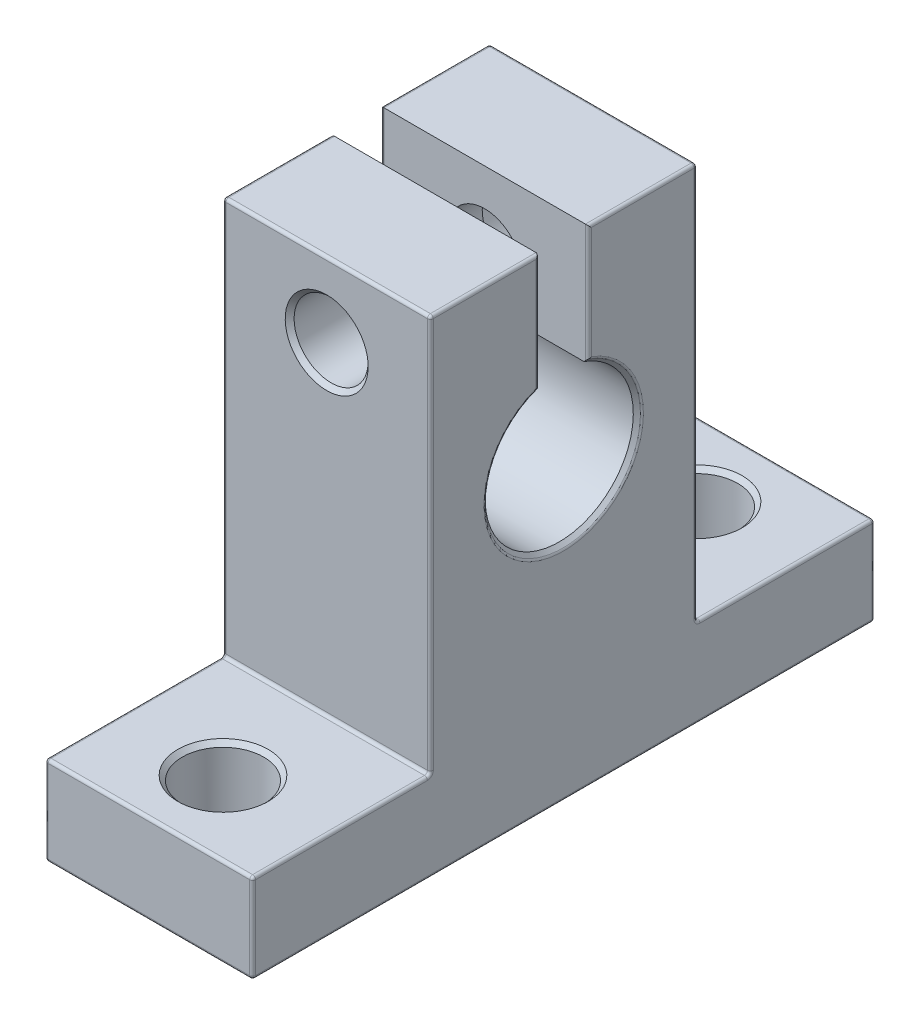
from build123d import *

# Parameters (mm, degrees)
BOSS_EXTRUDE1_DEPTH = 7
SKETCH2_R           = 2.75
CUT_EXTRUDE1_DEPTH  = 7
SKETCH3_R           = 2.5
CUT_EXTRUDE2_DEPTH  = 31
SKETCH4_R           = 4
CUT_EXTRUDE3_DEPTH  = 5
CHAMFER_1_SIZE      = 0.3
FILLET_1_R          = 0.2


with BuildPart() as part:
    # Sketch1 → Boss-Extrude1 (new body, symmetric)
    with BuildSketch(Plane(origin=(0, 0, 0), x_dir=(0, 0, -1), z_dir=(1, 0, 0))):
        with BuildLine():
            Line((-21, 0), (21, 0))
            Line((21, 0), (21, 6))
            Line((21, 6), (9, 6))
            Line((9, 6), (9, 32.8))
            Line((9, 32.8), (1.666666667, 32.8))
            Line((1.666666667, 32.8), (1.666666667, 24.714045208))
            ThreePointArc((1.666666667, 24.714045208), (0, 15), (-1.666666667, 24.714045208))
            Line((-1.666666667, 24.714045208), (-1.666666667, 32.8))
            Line((-1.666666667, 32.8), (-9, 32.8))
            Line((-9, 32.8), (-9, 6))
            Line((-9, 6), (-21, 6))
            Line((-21, 6), (-21, 0))
        make_face()
    extrude(amount=BOSS_EXTRUDE1_DEPTH, both=True)

    # Sketch2 → Cut-Extrude1 (cut, through all)
    with BuildSketch(Plane(origin=(0, 6, 0), x_dir=(1, 0, 0), z_dir=(0, 1, 0))):
        with Locations(Location((0, 16, 0), (0, 0, 270))):  # turned: the seam where the file's is
            Circle(SKETCH2_R)
        with Locations(Location((0, -16, 0), (0, 0, 270))):  # turned: the seam where the file's is
            Circle(SKETCH2_R)
    extrude(amount=-CUT_EXTRUDE1_DEPTH, mode=Mode.SUBTRACT)

    # Sketch3 → Cut-Extrude2 (cut, through all)
    with BuildSketch(Plane(origin=(0, 0, -9), x_dir=(-1, 0, 0), z_dir=(0, 0, -1))):
        with Locations(Location((0, 27.8, 0), (0, 0, 90))):  # turned: the seam where the file's is
            Circle(SKETCH3_R)
    extrude(amount=-CUT_EXTRUDE2_DEPTH, mode=Mode.SUBTRACT)

    # Sketch4 → Cut-Extrude3 (cut)
    with BuildSketch(Plane(origin=(0, 0, -9), x_dir=(-1, 0, 0), z_dir=(0, 0, -1))):
        with Locations((0, 27.8)):
            Circle(SKETCH4_R)
    extrude(amount=-CUT_EXTRUDE3_DEPTH, mode=Mode.SUBTRACT)

    # Фаска1
    chamfer_1_edges = [part.edges().sort_by_distance(p)[0] for p in [
        (7, 15, 0),
        (0, 0, -18.75),
        (0, 6, -18.75),
        (0, 0, 13.25),
        (0, 6, 13.25),
        (0, 25.3, 9),
        (4, 27.8, -9),
    ]]
    chamfer(chamfer_1_edges, length=CHAMFER_1_SIZE)

    # Скругление1
    fillet_1_edges = [part.edges().sort_by_distance(p)[0] for p in [
        (-7, 0, 0),
        (-7, 3, -21),
        (-7, 6, -15),
        (-7, 19.4, -9),
        (-7, 32.8, -5.333333333),
        (-7, 28.757022604, -1.666666667),
        (-7, 15, 0),
        (-7, 28.757022604, 1.666666667),
        (-7, 32.8, 5.333333333),
        (-7, 19.4, 9),
        (-7, 6, 15),
        (-7, 3, 21),
        (7, 32.8, -5.333333333),
        (7, 19.4, -9),
        (7, 6, -15),
        (7, 3, -21),
        (7, 0, 0),
        (7, 3, 21),
        (7, 6, 15),
        (7, 19.4, 9),
        (7, 32.8, 5.333333333),
        (7, 28.915562672, 1.666666667),
        (7, 14.7, 0),
        (7, 28.915562672, -1.666666667),
        (0, 0, 21),
        (0, 6, 21),
        (0, 6, 9),
        (0, 32.8, 9),
        (0, 0, -21),
        (0, 32.8, -9),
        (0, 6, -9),
        (0, 6, -21),
    ]]
    fillet(fillet_1_edges, radius=FILLET_1_R)


solid = part.part
